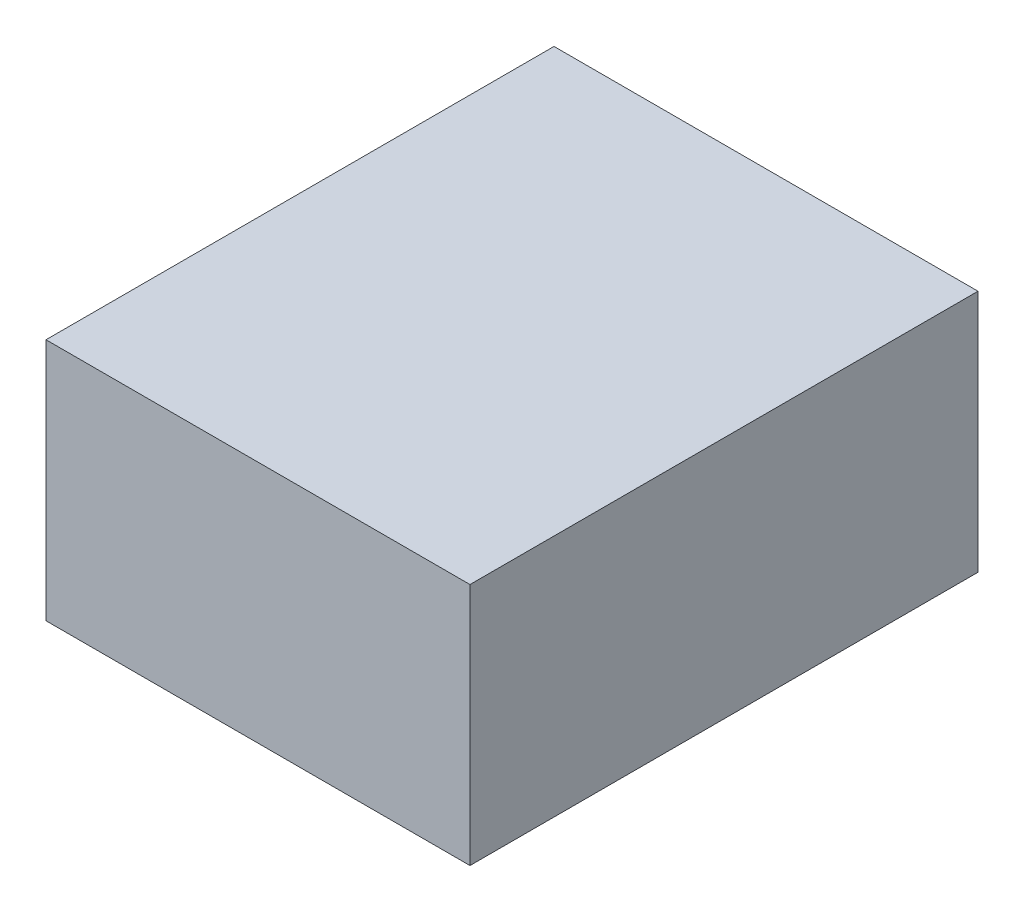
from build123d import *

# Parameters (mm, degrees)
SKETCH1_W           = 87.098324914
SKETCH1_H           = 104.364310218
BOSS_EXTRUDE1_DEPTH = 50


with BuildPart() as part:
    # Sketch1 → Boss-Extrude1 (new body)
    with BuildSketch(Plane(origin=(0, 0, 0), x_dir=(1, 0, 0), z_dir=(0, 1, 0))):
        Rectangle(SKETCH1_W, SKETCH1_H)
    extrude(amount=BOSS_EXTRUDE1_DEPTH)


solid = part.part
